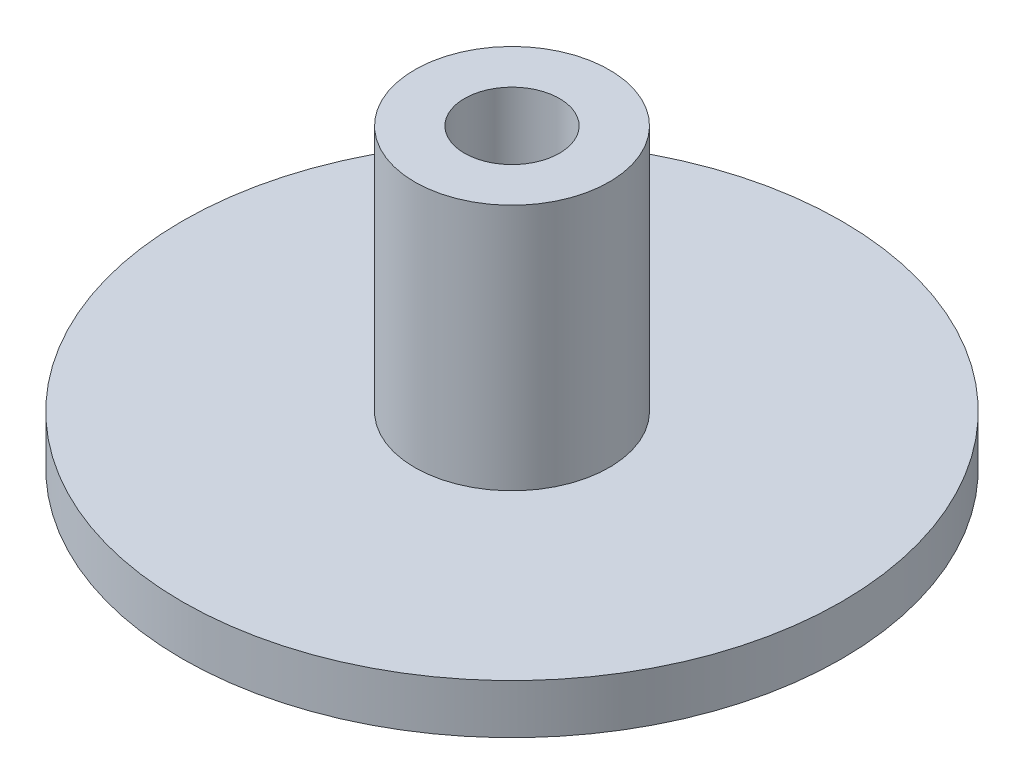
from build123d import *

# Parameters (mm, degrees)
ESQUISSE1_R        = 10
ESQUISSE1_R_2      = 2.95
BOSS_EXTRU_2_DEPTH = 1.5
ESQUISSE1_5_R      = 2.95
ESQUISSE1_5_R_2    = 1.44
BOSS_EXTRU_3_DEPTH = 9


with BuildPart() as part:
    # Esquisse1 → Boss.-Extru.2 (new body)
    with BuildSketch(Plane(origin=(0, 0, 0), x_dir=(1, 0, 0), z_dir=(0, 1, 0))):
        Circle(ESQUISSE1_R)
        Circle(ESQUISSE1_R_2, mode=Mode.SUBTRACT)
    extrude(amount=BOSS_EXTRU_2_DEPTH)

    # Esquisse1_5 → Boss.-Extru.3 (add)
    with BuildSketch(Plane(origin=(0, 0, 0), x_dir=(1, 0, 0), z_dir=(0, 1, 0))):
        Circle(ESQUISSE1_5_R)
        Circle(ESQUISSE1_5_R_2, mode=Mode.SUBTRACT)
    extrude(amount=BOSS_EXTRU_3_DEPTH)


solid = part.part
